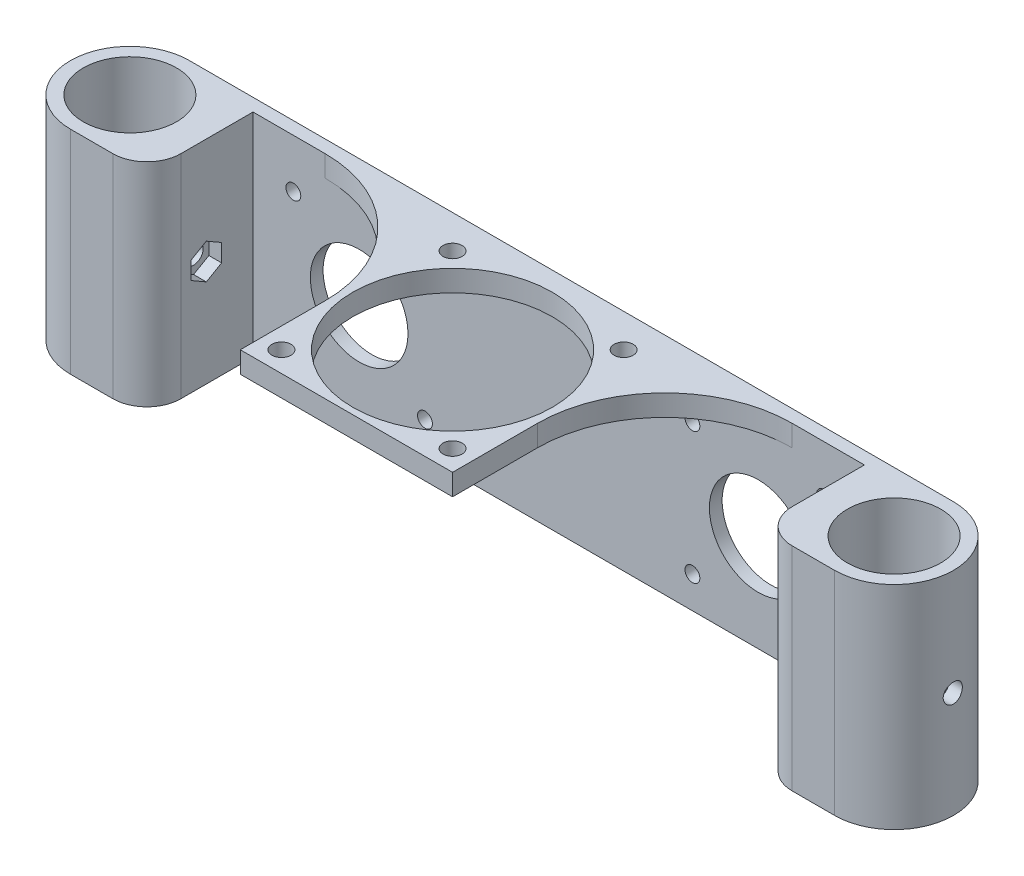
from build123d import *

# Parameters (mm, degrees)
SKETCH1_R               = 11
BOSS_EXTRUDE1_DEPTH     = 50
FILLET1_R               = 8
SKETCH2_R               = 11.5
SKETCH2_R_2             = 1.75
CUT_EXTRUDE1_DEPTH      = 10
SKETCH3_W               = 50
SKETCH3_H               = 5
BOSS_EXTRUDE2_DEPTH     = 50
SKETCH4_R               = 23.5
SKETCH4_R_2             = 2.25
CUT_EXTRUDE2_DEPTH      = 50
FILLET2_R               = 30
SKETCH6_R               = 2.25
CUT_EXTRUDE3_DEPTH      = 197
CUT_EXTRUDE3_DEPTH_BACK = 13
CUT_EXTRUDE4_DEPTH      = 3


with BuildPart() as part:
    # Sketch1 → Boss-Extrude1 (new body)
    with BuildSketch(Plane(origin=(0, 0, 0), x_dir=(1, 0, 0), z_dir=(0, 1, 0))):
        with BuildLine():
            Line((137.460581558, -14.5), (119.460581558, -14.5))
            Line((119.460581558, -14.5), (119.460581558, 10.5))
            Line((119.460581558, 10.5), (-24.539418442, 10.5))
            Line((-24.539418442, 10.5), (-24.539418442, -14.5))
            Line((-24.539418442, -14.5), (-42.539418442, -14.5))
            ThreePointArc((-42.539418442, -14.5), (-56.539418442, -0.5), (-42.539418442, 13.5))
            Line((-42.539418442, 13.5), (137.460581558, 13.5))
            ThreePointArc((137.460581558, 13.5), (151.460581558, -0.5), (137.460581558, -14.5))
        make_face()
        with Locations((-42.539418442, -0.5)):
            Circle(SKETCH1_R, mode=Mode.SUBTRACT)
        with Locations((137.460581558, -0.5)):
            Circle(SKETCH1_R, mode=Mode.SUBTRACT)
    extrude(amount=BOSS_EXTRUDE1_DEPTH)

    # Fillet1
    fillet1_edges = [part.edges().sort_by_distance(p)[0] for p in [
        (119.460581558, 25, 14.5),
        (-24.539418442, 25, 14.5),
    ]]
    fillet(fillet1_edges, radius=FILLET1_R)

    # Sketch2 → Cut-Extrude1 (cut)
    with BuildSketch(Plane.XY.offset(-10.5)):
        with Locations((0.460581558, 23)):
            Circle(SKETCH2_R)
        with Locations((15.960581558, 7.5)):
            Circle(SKETCH2_R_2)
        with Locations((-15.039418442, 7.5)):
            Circle(SKETCH2_R_2)
        with Locations((-15.039418442, 38.5)):
            Circle(SKETCH2_R_2)
        with Locations((15.960581558, 38.5)):
            Circle(SKETCH2_R_2)
        with Locations((78.960581558, 38.5)):
            Circle(SKETCH2_R_2)
        with Locations((109.960581558, 38.5)):
            Circle(SKETCH2_R_2)
        with Locations((109.960581558, 7.5)):
            Circle(SKETCH2_R_2)
        with Locations((94.460581558, 23)):
            Circle(SKETCH2_R)
        with Locations((78.960581558, 7.5)):
            Circle(SKETCH2_R_2)
    extrude(amount=-CUT_EXTRUDE1_DEPTH, mode=Mode.SUBTRACT)

    # Sketch3 → Boss-Extrude2 (add)
    with BuildSketch(Plane.XY.offset(-10.5)):
        with Locations((47.460581558, 47.5)):
            Rectangle(SKETCH3_W, SKETCH3_H)
    extrude(amount=BOSS_EXTRUDE2_DEPTH)

    # Sketch4 → Cut-Extrude2 (cut)
    with BuildSketch(Plane(origin=(0, 45, 0), x_dir=(-1, 0, 0), z_dir=(0, -1, 0))):
        with Locations((-47.460581558, -14.5)):
            Circle(SKETCH4_R)
        with Locations((-67.613124822, 5.652543264)):
            Circle(SKETCH4_R_2)
        with Locations((-27.308038294, 5.652543264)):
            Circle(SKETCH4_R_2)
        with Locations((-27.308038294, -34.652543264)):
            Circle(SKETCH4_R_2)
        with Locations((-67.613124822, -34.652543264)):
            Circle(SKETCH4_R_2)
    extrude(amount=-CUT_EXTRUDE2_DEPTH, mode=Mode.SUBTRACT)

    # Fillet2
    fillet2_edges = [part.edges().sort_by_distance(p)[0] for p in [
        (72.460581558, 47.5, -10.5),
        (22.460581558, 47.5, -10.5),
    ]]
    fillet(fillet2_edges, radius=FILLET2_R)

    # Sketch6 → Cut-Extrude3 (cut, two sides)
    with BuildSketch(Plane.ZY.offset(-139.460581558)) as cut_extrude3_sk:
        with Locations((0.5, 25)):
            Circle(SKETCH6_R)
    extrude(amount=CUT_EXTRUDE3_DEPTH, mode=Mode.SUBTRACT)
    extrude(cut_extrude3_sk.sketch, amount=-CUT_EXTRUDE3_DEPTH_BACK, mode=Mode.SUBTRACT)

    # Sketch7 → Cut-Extrude4 (cut)
    with BuildSketch(Plane(origin=(-24.539418442, 0, 0), x_dir=(0, 0, -1), z_dir=(1, 0, 0))):
        Polygon((-0.5, 20.843078062), (3.1, 22.921539031), (3.1, 27.078460969), (-0.5, 29.156921938), (-4.1, 27.078460969), (-4.1, 22.921539031), align=None)
    cut_extrude4 = extrude(amount=-CUT_EXTRUDE4_DEPTH, mode=Mode.SUBTRACT)

    # Mirror1: Cut-Extrude4 across plane
    add(cut_extrude4.mirror(Plane.ZY.offset(-47.460581558)), mode=Mode.SUBTRACT)


solid = part.part
